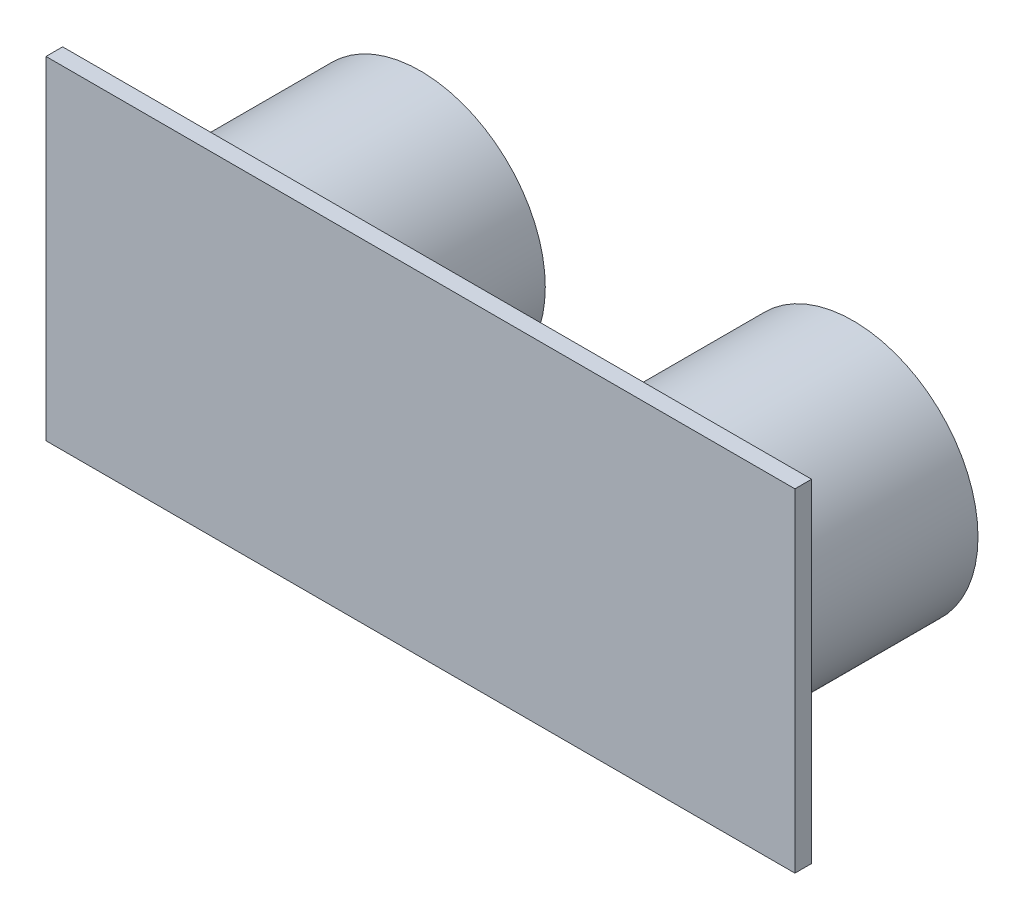
from build123d import *

# Parameters (mm, degrees)
SKETCH1_W           = 45
SKETCH1_H           = 20
BOSS_EXTRUDE1_DEPTH = 1
SKETCH2_R           = 7.5
SKETCH2_R_2         = 6.5
BOSS_EXTRUDE2_DEPTH = 12
SKETCH3_R           = 6.5
BOSS_EXTRUDE3_DEPTH = 10


with BuildPart() as part:
    # Sketch1 → Boss-Extrude1 (new body)
    with BuildSketch(Plane.XY):
        with Locations((-3.47266881, 2.258842444)):
            Rectangle(SKETCH1_W, SKETCH1_H)
    extrude(amount=BOSS_EXTRUDE1_DEPTH)

    # Sketch2 → Boss-Extrude2 (add)
    with BuildSketch(Plane.XY):
        with Locations((-16.47266881, 2.258842444)):
            Circle(SKETCH2_R)
        with Locations((-16.47266881, 2.258842444)):
            Circle(SKETCH2_R_2, mode=Mode.SUBTRACT)
        with Locations((9.52733119, 2.258842444)):
            Circle(SKETCH2_R)
        with Locations((9.52733119, 2.258842444)):
            Circle(SKETCH2_R_2, mode=Mode.SUBTRACT)
    extrude(amount=-BOSS_EXTRUDE2_DEPTH)

    # Sketch3 → Boss-Extrude3 (add)
    with BuildSketch(Plane.XY):
        with Locations((9.52733119, 2.258842444)):
            Circle(SKETCH3_R)
        with Locations((-16.47266881, 2.258842444)):
            Circle(SKETCH3_R)
    extrude(amount=-BOSS_EXTRUDE3_DEPTH)


solid = part.part
